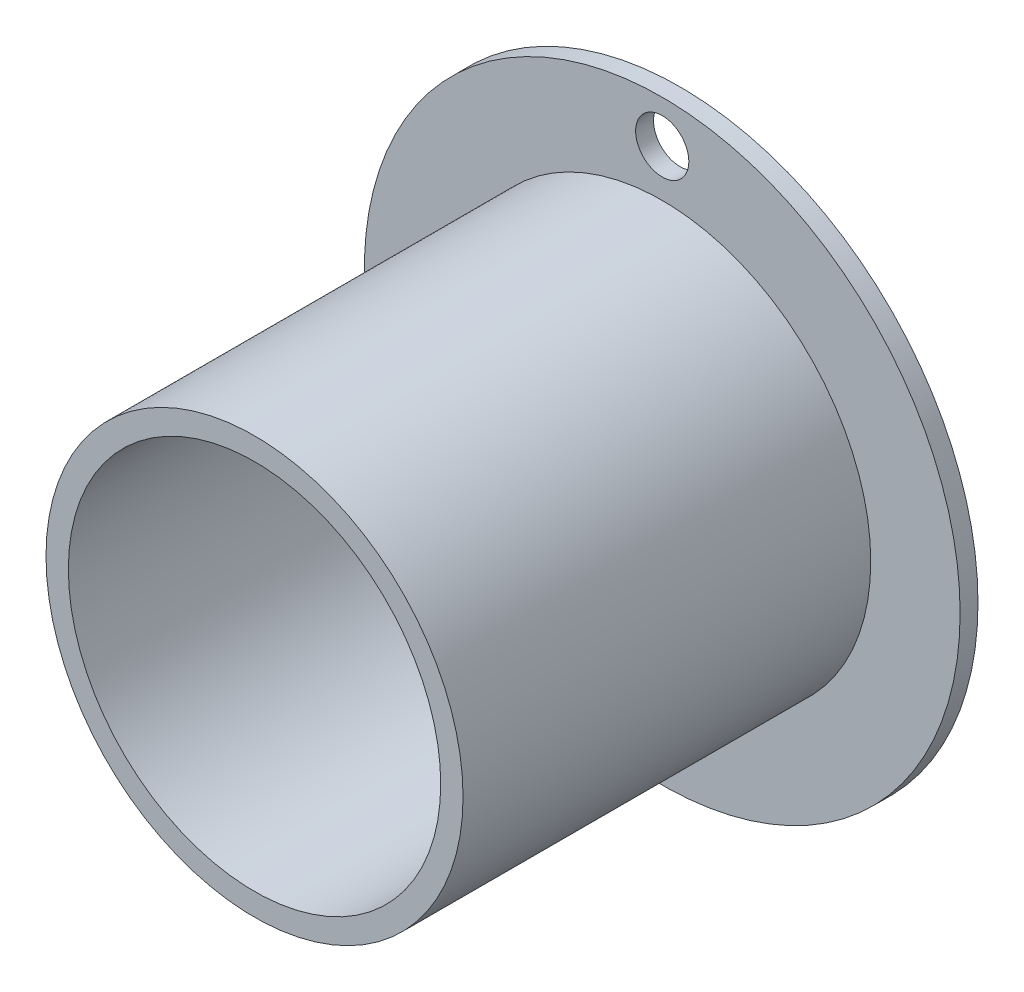
from build123d import *

# Parameters (mm, degrees)
SKETCH1_R                    = 17.78
SKETCH1_R_2                  = 11.1125
BOSS_EXTRUDE1_DEPTH          = 25.4
CUT_EXTRUDE1_START           = -24.3332
SKETCH2_OUTSIDE_W            = 48.828
SKETCH2_OUTSIDE_H            = 48.828
SKETCH2_OUTSIDE_R            = 12.446
CUT_EXTRUDE1_DEPTH           = 24.3332
F_1_8_0_125_DIAMETER_HOLE1_D = 3.175


with BuildPart() as part:
    # Sketch1 → Boss-Extrude1 (new body)
    with BuildSketch(Plane.XY):
        Circle(SKETCH1_R)
        Circle(SKETCH1_R_2, mode=Mode.SUBTRACT)
    extrude(amount=BOSS_EXTRUDE1_DEPTH)

    # Sketch2 outside → Cut-Extrude1 (cut)
    with BuildSketch(Plane.XY.offset(25.4).offset(CUT_EXTRUDE1_START)):
        Rectangle(SKETCH2_OUTSIDE_W, SKETCH2_OUTSIDE_H)
        Circle(SKETCH2_OUTSIDE_R, mode=Mode.SUBTRACT)
    extrude(amount=CUT_EXTRUDE1_DEPTH, mode=Mode.SUBTRACT)

    # 1/8 (0.125) Diameter Hole1 (through all)
    with Locations(Plane.XY.offset(1.0668)):
        with Locations((0, 15.24)):
            f_1_8_0_125_diameter_hole1 = Hole(F_1_8_0_125_DIAMETER_HOLE1_D / 2)

    # Mirror1: 1/8 (0.125) Diameter Hole1 across plane
    add(f_1_8_0_125_diameter_hole1.mirror(Plane.ZX), mode=Mode.SUBTRACT)


solid = part.part
